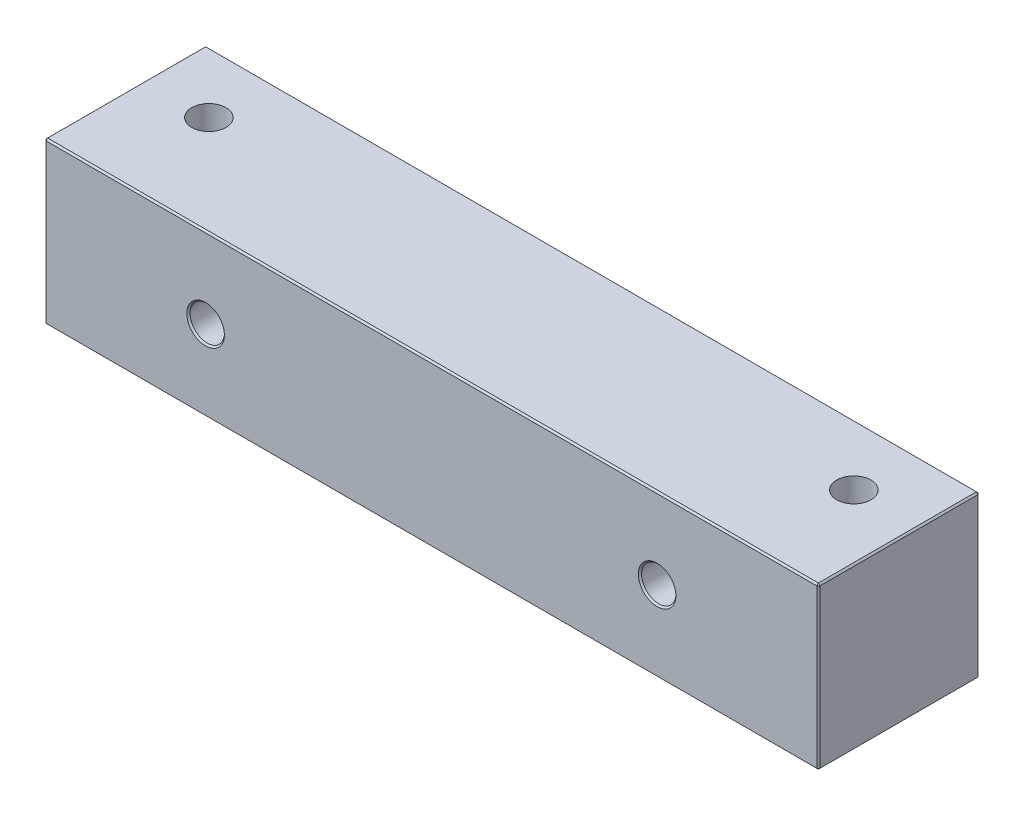
from build123d import *

# Parameters (mm, degrees)
SKETCH1_W             = 60.96
SKETCH1_H             = 12.7
BOSS_EXTRUDE1_DEPTH   = 6.35
F_6_32_TAPPED_HOLE1_D = 2.7051
F_6_32_TAPPED_HOLE2_D = 2.7051
CHAMFER1_SIZE         = 0.127


with BuildPart() as part:
    # Sketch1 → Boss-Extrude1 (new body, symmetric)
    with BuildSketch(Plane(origin=(0, 0, 0), x_dir=(1, 0, 0), z_dir=(0, 1, 0))):
        Rectangle(SKETCH1_W, SKETCH1_H)
    extrude(amount=BOSS_EXTRUDE1_DEPTH, both=True)

    # #6-32 Tapped Hole1 (through all)
    with Locations(Plane(origin=(0, 6.35, 0), x_dir=(1, 0, 0), z_dir=(0, 1, 0))):
        with Locations((-25.4, 1.524), (25.4, 1.524)):
            Hole(F_6_32_TAPPED_HOLE1_D / 2)

    # #6-32 Tapped Hole2 (through all)
    with Locations(Plane.XY.offset(6.35)):
        with Locations((-17.78, 0), (17.78, 0)):
            Hole(F_6_32_TAPPED_HOLE2_D / 2)

    # Chamfer1
    chamfer1_edges = [part.edges().sort_by_distance(p)[0] for p in [
        (-30.48, 6.35, 0),
        (0, 6.35, 6.35),
        (19.13255, 0, 6.35),
        (19.13255, 0, -6.35),
        (-16.42745, 0, 6.35),
        (-16.42745, 0, -6.35),
        (30.48, 6.35, 0),
        (0, -6.35, 6.35),
        (-30.48, -6.35, 0),
        (0, -6.35, -6.35),
        (30.48, -6.35, 0),
        (0, 6.35, -6.35),
        (30.48, 0, 6.35),
        (-30.48, 0, 6.35),
        (-30.48, 0, -6.35),
        (30.48, 0, -6.35),
    ]]
    chamfer(chamfer1_edges, length=CHAMFER1_SIZE)


solid = part.part
